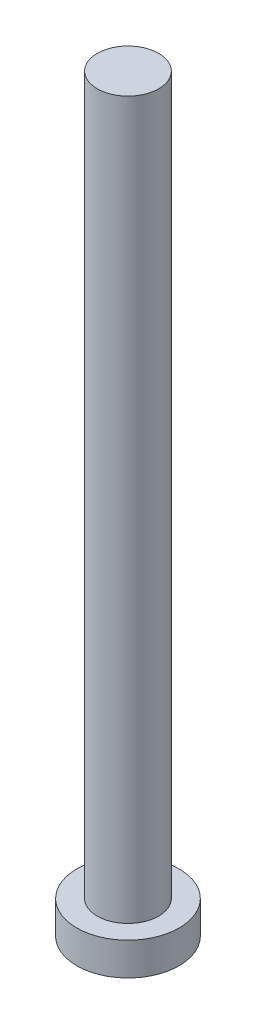
from build123d import *

# Parameters (mm, degrees)
SKETCH_1_R          = 2.5
EXTRUDE_1_DEPTH     = 1.6
SKETCH_2_R          = 1.5
EXTRUDE_2_DEPTH     = 35
CUT_EXTRUDE_1_DEPTH = 1


with BuildPart() as part:
    # 草图1 → 凸台-拉伸1 (new body)
    with BuildSketch(Plane(origin=(0, 0, 0), x_dir=(1, 0, 0), z_dir=(0, 1, 0))):
        Circle(SKETCH_1_R)
    extrude(amount=EXTRUDE_1_DEPTH)

    # 草图2 → 凸台-拉伸2 (add)
    with BuildSketch(Plane(origin=(0, 1.6, 0), x_dir=(1, 0, 0), z_dir=(0, 1, 0))):
        Circle(SKETCH_2_R)
    extrude(amount=EXTRUDE_2_DEPTH)

    # 草图3 → 切除-拉伸1 (cut)
    with BuildSketch(Plane.XZ):
        with BuildLine():
            Line((-0.5, 1), (-0.5, 1.75))
            Line((-0.5, 1.75), (0.5, 1.75))
            Line((0.5, 1.75), (0.5, 1))
            ThreePointArc((0.5, 1), (0.646446609, 0.646446609), (1, 0.5))
            Line((1, 0.5), (1.75, 0.5))
            Line((1.75, 0.5), (1.75, -0.5))
            Line((1.75, -0.5), (1, -0.5))
            ThreePointArc((1, -0.5), (0.646446609, -0.646446609), (0.5, -1))
            Line((0.5, -1), (0.5, -1.75))
            Line((0.5, -1.75), (-0.5, -1.75))
            Line((-0.5, -1.75), (-0.5, -1))
            ThreePointArc((-0.5, -1), (-0.646446609, -0.646446609), (-1, -0.5))
            Line((-1, -0.5), (-1.75, -0.5))
            Line((-1.75, -0.5), (-1.75, 0.5))
            Line((-1.75, 0.5), (-1, 0.5))
            ThreePointArc((-1, 0.5), (-0.646446609, 0.646446609), (-0.5, 1))
        make_face()
    extrude(amount=-CUT_EXTRUDE_1_DEPTH, mode=Mode.SUBTRACT)


solid = part.part
